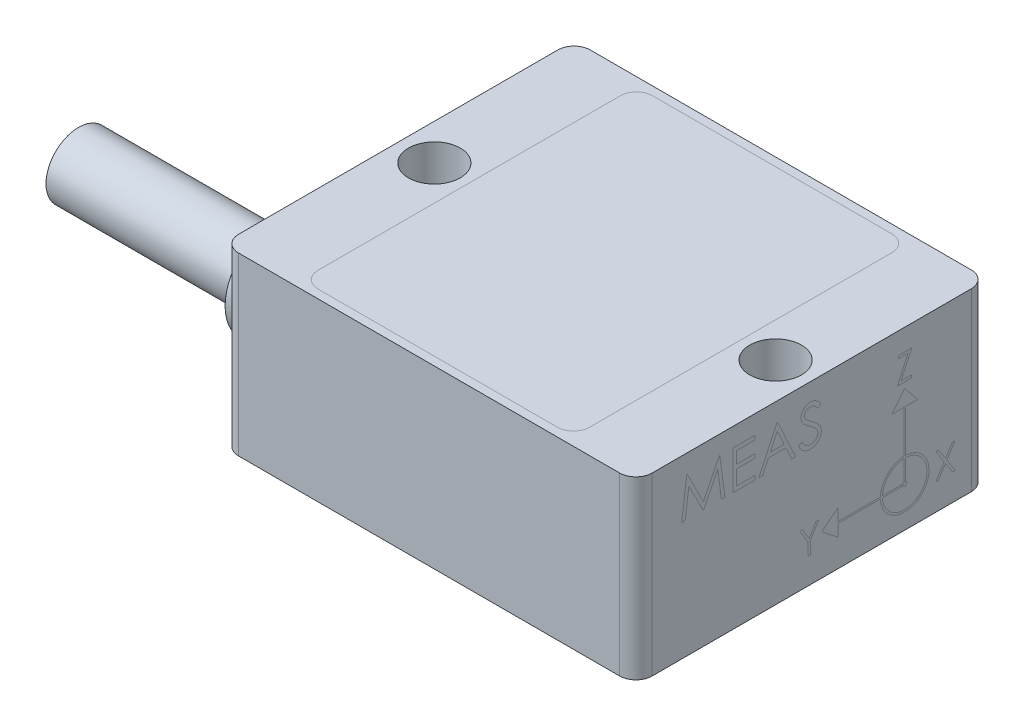
from build123d import *

# Parameters (mm, degrees)
SKETCH1_W           = 25.4
SKETCH1_H           = 21.6
SKETCH1_R           = 1.59
BOSS_EXTRUDE1_DEPTH = 5.4
SKETCH3_R           = 3
BOSS_EXTRUDE2_DEPTH = 2
SKETCH4_R           = 2
BOSS_EXTRUDE3_DEPTH = 12
FILLET1_R           = 1


with BuildPart() as part:
    # Sketch1 → Boss-Extrude1 (new body, symmetric)
    with BuildSketch(Plane(origin=(0, 0, 0), x_dir=(1, 0, 0), z_dir=(0, 1, 0))):
        Rectangle(SKETCH1_W, SKETCH1_H)
        with Locations((-10.48, 0)):
            Circle(SKETCH1_R, mode=Mode.SUBTRACT)
        with Locations((10.48, 0)):
            Circle(SKETCH1_R, mode=Mode.SUBTRACT)
    extrude(amount=BOSS_EXTRUDE1_DEPTH, both=True)

    # Sketch3 → Boss-Extrude2 (add)
    with BuildSketch(Plane.ZY.offset(12.7)):
        with Locations((5.632237715, 0)):
            Circle(SKETCH3_R)
    extrude(amount=BOSS_EXTRUDE2_DEPTH)

    # Sketch4 → Boss-Extrude3 (add)
    with BuildSketch(Plane.ZY.offset(14.7)):
        with Locations((5.632237715, 0)):
            Circle(SKETCH4_R)
    extrude(amount=BOSS_EXTRUDE3_DEPTH)

    # Fillet1
    fillet1_edges = [part.edges().sort_by_distance(p)[0] for p in [
        (12.7, 0, 10.8),
        (-12.7, 0, 10.8),
        (-12.7, 0, -10.8),
        (12.7, 0, -10.8),
    ]]
    fillet(fillet1_edges, radius=FILLET1_R)


solid = part.part
